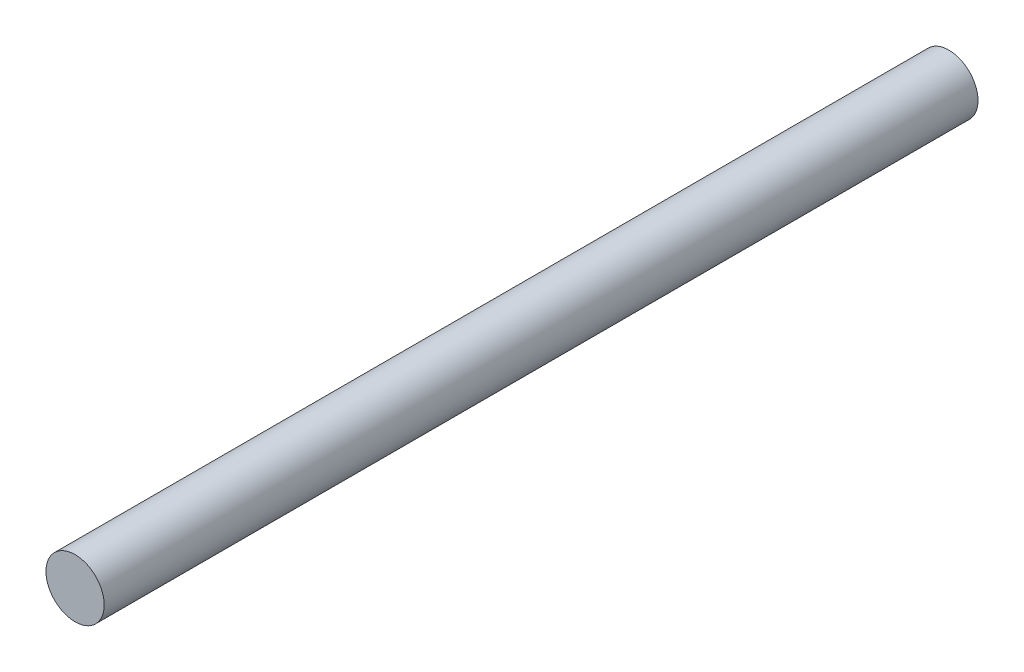
from build123d import *

# Parameters (mm, degrees)
SKETCH1_R           = 4
BOSS_EXTRUDE1_DEPTH = 120


with BuildPart() as part:
    # Sketch1 → Boss-Extrude1 (new body)
    with BuildSketch(Plane.XY):
        Circle(SKETCH1_R)
    extrude(amount=BOSS_EXTRUDE1_DEPTH)


solid = part.part
